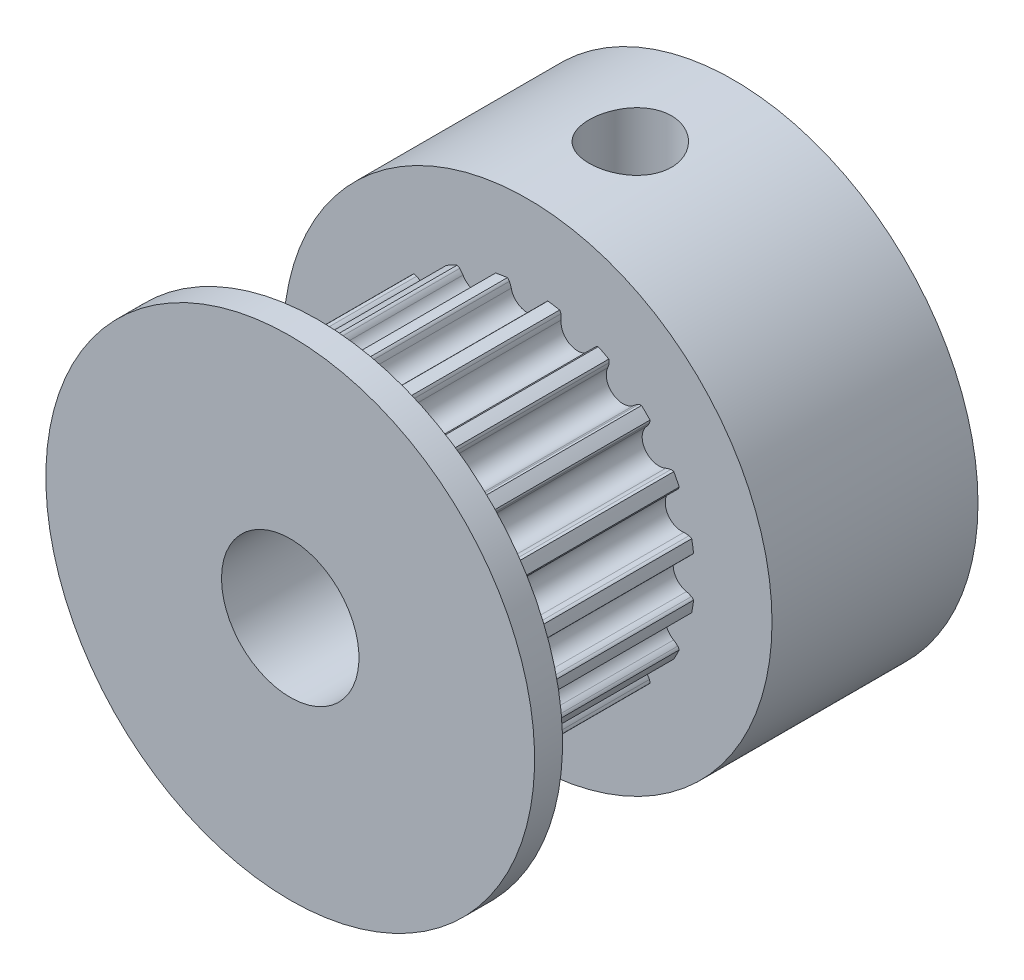
from build123d import *

# Parameters (mm, degrees)
CROQUIS1_W              = 8.89
CROQUIS1_H              = 7.493
SALIENTE_EXTRUIR1_DEPTH = 7.62
CROQUIS3_R              = 8.89
SALIENTE_EXTRUIR2_DEPTH = 1.016
TALADRO1_D              = 5
CROQUIS6_W              = 1.4986
CROQUIS6_H              = 6.09092461
CROQUIS8_W              = 1.4986
CROQUIS8_H              = 6.09092461


with BuildPart() as part:
    # Croquis1 → Revolución1 (revolve)
    with BuildSketch(Plane.XZ.offset(-159)):
        with Locations((120.445, 165.896175008)):
            Rectangle(CROQUIS1_W, CROQUIS1_H)
    revolve(axis=Axis((116, 159, 169.642675008), (0, 0, -1)))

    # Croquis2 → Saliente-Extruir1 (add)
    with BuildSketch(Plane.XY.offset(169.642675008)):
        with BuildLine():
            ThreePointArc((112.121956932, 163.323311365), (112.887977513, 163.283331488), (113.086667767, 164.024214814))
            ThreePointArc((113.086667767, 164.024214814), (113.054039722, 164.114885311), (113.03495398, 164.209338807))
            ThreePointArc((113.03495398, 164.209338807), (113.034584378, 164.263879911), (113.04714549, 164.31695615))
            ThreePointArc((113.04714549, 164.31695615), (113.238880224, 164.419002679), (113.43413645, 164.514137893))
            ThreePointArc((113.43413645, 164.514137893), (113.484459265, 164.493102615), (113.528366698, 164.460745144))
            ThreePointArc((113.528366698, 164.460745144), (113.593562865, 164.389786083), (113.647738554, 164.310094658))
            ThreePointArc((113.647738554, 164.310094658), (114.363912957, 164.035358158), (114.781824157, 164.678581408))
            ThreePointArc((114.781824157, 164.678581408), (114.778811766, 164.774896796), (114.789847882, 164.870625227))
            ThreePointArc((114.789847882, 164.870625227), (114.806350498, 164.922611113), (114.834698285, 164.969208019))
            ThreePointArc((114.834698285, 164.969208019), (115.048582965, 165.007010744), (115.263681069, 165.037152217))
            ThreePointArc((115.263681069, 165.037152217), (115.305040652, 165.001595874), (115.336800094, 164.957253947))
            ThreePointArc((115.336800094, 164.957253947), (115.376877777, 164.869621146), (115.403775915, 164.777088889))
            ThreePointArc((115.403775915, 164.777088889), (116, 164.294488889), (116.596224085, 164.777088889))
            ThreePointArc((116.596224085, 164.777088889), (116.623122223, 164.869621146), (116.663199906, 164.957253947))
            ThreePointArc((116.663199906, 164.957253947), (116.694959348, 165.001595874), (116.736318931, 165.037152217))
            ThreePointArc((116.736318931, 165.037152217), (116.951417035, 165.007010744), (117.165301715, 164.969208019))
            ThreePointArc((117.165301715, 164.969208019), (117.193649502, 164.922611113), (117.210152118, 164.870625227))
            ThreePointArc((117.210152118, 164.870625227), (117.221188234, 164.774896796), (117.218175843, 164.678581408))
            ThreePointArc((117.218175843, 164.678581408), (117.636087043, 164.035358158), (118.352261446, 164.310094658))
            ThreePointArc((118.352261446, 164.310094658), (118.406437135, 164.389786083), (118.471633302, 164.460745144))
            ThreePointArc((118.471633302, 164.460745144), (118.515540735, 164.493102615), (118.56586355, 164.514137893))
            ThreePointArc((118.56586355, 164.514137893), (118.761119776, 164.419002679), (118.95285451, 164.31695615))
            ThreePointArc((118.95285451, 164.31695615), (118.965415622, 164.263879911), (118.96504602, 164.209338807))
            ThreePointArc((118.96504602, 164.209338807), (118.945960278, 164.114885311), (118.913332233, 164.024214814))
            ThreePointArc((118.913332233, 164.024214814), (119.112022487, 163.283331488), (119.878043068, 163.323311365))
            ThreePointArc((119.878043068, 163.323311365), (119.954193214, 163.382361205), (120.038126009, 163.429700559))
            ThreePointArc((120.038126009, 163.429700559), (120.089883468, 163.4469062), (120.144243567, 163.451361332))
            ThreePointArc((120.144243567, 163.451361332), (120.300544876, 163.300544876), (120.451361332, 163.144243567))
            ThreePointArc((120.451361332, 163.144243567), (120.4469062, 163.089883468), (120.429700559, 163.038126009))
            ThreePointArc((120.429700559, 163.038126009), (120.382361205, 162.954193214), (120.323311365, 162.878043068))
            ThreePointArc((120.323311365, 162.878043068), (120.283331488, 162.112022487), (121.024214814, 161.913332233))
            ThreePointArc((121.024214814, 161.913332233), (121.114885311, 161.945960278), (121.209338807, 161.96504602))
            ThreePointArc((121.209338807, 161.96504602), (121.263879911, 161.965415622), (121.31695615, 161.95285451))
            ThreePointArc((121.31695615, 161.95285451), (121.419002679, 161.761119776), (121.514137893, 161.56586355))
            ThreePointArc((121.514137893, 161.56586355), (121.493102615, 161.515540735), (121.460745144, 161.471633302))
            ThreePointArc((121.460745144, 161.471633302), (121.389786083, 161.406437135), (121.310094658, 161.352261446))
            ThreePointArc((121.310094658, 161.352261446), (121.035358158, 160.636087043), (121.678581408, 160.218175843))
            ThreePointArc((121.678581408, 160.218175843), (121.774896796, 160.221188234), (121.870625227, 160.210152118))
            ThreePointArc((121.870625227, 160.210152118), (121.922611113, 160.193649502), (121.969208019, 160.165301715))
            ThreePointArc((121.969208019, 160.165301715), (122.007010744, 159.951417035), (122.037152217, 159.736318931))
            ThreePointArc((122.037152217, 159.736318931), (122.001595874, 159.694959348), (121.957253947, 159.663199906))
            ThreePointArc((121.957253947, 159.663199906), (121.869621146, 159.623122223), (121.777088889, 159.596224085))
            ThreePointArc((121.777088889, 159.596224085), (121.294488889, 159), (121.777088889, 158.403775915))
            ThreePointArc((121.777088889, 158.403775915), (121.869621146, 158.376877777), (121.957253947, 158.336800094))
            ThreePointArc((121.957253947, 158.336800094), (122.001595874, 158.305040652), (122.037152217, 158.263681069))
            ThreePointArc((122.037152217, 158.263681069), (122.007010744, 158.048582965), (121.969208019, 157.834698285))
            ThreePointArc((121.969208019, 157.834698285), (121.922611113, 157.806350498), (121.870625227, 157.789847882))
            ThreePointArc((121.870625227, 157.789847882), (121.774896796, 157.778811766), (121.678581408, 157.781824157))
            ThreePointArc((121.678581408, 157.781824157), (121.035358158, 157.363912957), (121.310094658, 156.647738554))
            ThreePointArc((121.310094658, 156.647738554), (121.389786083, 156.593562865), (121.460745144, 156.528366698))
            ThreePointArc((121.460745144, 156.528366698), (121.493102615, 156.484459265), (121.514137893, 156.43413645))
            ThreePointArc((121.514137893, 156.43413645), (121.419002679, 156.238880224), (121.31695615, 156.04714549))
            ThreePointArc((121.31695615, 156.04714549), (121.263879911, 156.034584378), (121.209338807, 156.03495398))
            ThreePointArc((121.209338807, 156.03495398), (121.114885311, 156.054039722), (121.024214814, 156.086667767))
            ThreePointArc((121.024214814, 156.086667767), (120.283331488, 155.887977513), (120.323311365, 155.121956932))
            ThreePointArc((120.323311365, 155.121956932), (120.382361205, 155.045806786), (120.429700559, 154.961873991))
            ThreePointArc((120.429700559, 154.961873991), (120.4469062, 154.910116532), (120.451361332, 154.855756433))
            ThreePointArc((120.451361332, 154.855756433), (120.300544876, 154.699455124), (120.144243567, 154.548638668))
            ThreePointArc((120.144243567, 154.548638668), (120.089883468, 154.5530938), (120.038126009, 154.570299441))
            ThreePointArc((120.038126009, 154.570299441), (119.954193214, 154.617638795), (119.878043068, 154.676688635))
            ThreePointArc((119.878043068, 154.676688635), (119.112022487, 154.716668512), (118.913332233, 153.975785186))
            ThreePointArc((118.913332233, 153.975785186), (118.945960278, 153.885114689), (118.96504602, 153.790661193))
            ThreePointArc((118.96504602, 153.790661193), (118.965415622, 153.736120089), (118.95285451, 153.68304385))
            ThreePointArc((118.95285451, 153.68304385), (118.761119776, 153.580997321), (118.56586355, 153.485862107))
            ThreePointArc((118.56586355, 153.485862107), (118.515540735, 153.506897385), (118.471633302, 153.539254856))
            ThreePointArc((118.471633302, 153.539254856), (118.406437135, 153.610213917), (118.352261446, 153.689905342))
            ThreePointArc((118.352261446, 153.689905342), (117.636087043, 153.964641842), (117.218175843, 153.321418592))
            ThreePointArc((117.218175843, 153.321418592), (117.221188234, 153.225103204), (117.210152118, 153.129374773))
            ThreePointArc((117.210152118, 153.129374773), (117.193649502, 153.077388887), (117.165301715, 153.030791981))
            ThreePointArc((117.165301715, 153.030791981), (116.951417035, 152.992989256), (116.736318931, 152.962847783))
            ThreePointArc((116.736318931, 152.962847783), (116.694959348, 152.998404126), (116.663199906, 153.042746053))
            ThreePointArc((116.663199906, 153.042746053), (116.623122223, 153.130378854), (116.596224085, 153.222911111))
            ThreePointArc((116.596224085, 153.222911111), (116, 153.705511111), (115.403775915, 153.222911111))
            ThreePointArc((115.403775915, 153.222911111), (115.376877777, 153.130378854), (115.336800094, 153.042746053))
            ThreePointArc((115.336800094, 153.042746053), (115.305040652, 152.998404126), (115.263681069, 152.962847783))
            ThreePointArc((115.263681069, 152.962847783), (115.048582965, 152.992989256), (114.834698285, 153.030791981))
            ThreePointArc((114.834698285, 153.030791981), (114.806350498, 153.077388887), (114.789847882, 153.129374773))
            ThreePointArc((114.789847882, 153.129374773), (114.778811766, 153.225103204), (114.781824157, 153.321418592))
            ThreePointArc((114.781824157, 153.321418592), (114.363912957, 153.964641842), (113.647738554, 153.689905342))
            ThreePointArc((113.647738554, 153.689905342), (113.593562865, 153.610213917), (113.528366698, 153.539254856))
            ThreePointArc((113.528366698, 153.539254856), (113.484459265, 153.506897385), (113.43413645, 153.485862107))
            ThreePointArc((113.43413645, 153.485862107), (113.238880224, 153.580997321), (113.04714549, 153.68304385))
            ThreePointArc((113.04714549, 153.68304385), (113.034584378, 153.736120089), (113.03495398, 153.790661193))
            ThreePointArc((113.03495398, 153.790661193), (113.054039722, 153.885114689), (113.086667767, 153.975785186))
            ThreePointArc((113.086667767, 153.975785186), (112.887977513, 154.716668512), (112.121956932, 154.676688635))
            ThreePointArc((112.121956932, 154.676688635), (112.045806786, 154.617638795), (111.961873991, 154.570299441))
            ThreePointArc((111.961873991, 154.570299441), (111.910116532, 154.5530938), (111.855756433, 154.548638668))
            ThreePointArc((111.855756433, 154.548638668), (111.699455124, 154.699455124), (111.548638668, 154.855756433))
            ThreePointArc((111.548638668, 154.855756433), (111.5530938, 154.910116532), (111.570299441, 154.961873991))
            ThreePointArc((111.570299441, 154.961873991), (111.617638795, 155.045806786), (111.676688635, 155.121956932))
            ThreePointArc((111.676688635, 155.121956932), (111.716668512, 155.887977513), (110.975785186, 156.086667767))
            ThreePointArc((110.975785186, 156.086667767), (110.885114689, 156.054039722), (110.790661193, 156.03495398))
            ThreePointArc((110.790661193, 156.03495398), (110.736120089, 156.034584378), (110.68304385, 156.04714549))
            ThreePointArc((110.68304385, 156.04714549), (110.580997321, 156.238880224), (110.485862107, 156.43413645))
            ThreePointArc((110.485862107, 156.43413645), (110.506897385, 156.484459265), (110.539254856, 156.528366698))
            ThreePointArc((110.539254856, 156.528366698), (110.610213917, 156.593562865), (110.689905342, 156.647738554))
            ThreePointArc((110.689905342, 156.647738554), (110.964641842, 157.363912957), (110.321418592, 157.781824157))
            ThreePointArc((110.321418592, 157.781824157), (110.225103204, 157.778811766), (110.129374773, 157.789847882))
            ThreePointArc((110.129374773, 157.789847882), (110.077388887, 157.806350498), (110.030791981, 157.834698285))
            ThreePointArc((110.030791981, 157.834698285), (109.992989256, 158.048582965), (109.962847783, 158.263681069))
            ThreePointArc((109.962847783, 158.263681069), (109.998404126, 158.305040652), (110.042746053, 158.336800094))
            ThreePointArc((110.042746053, 158.336800094), (110.130378854, 158.376877777), (110.222911111, 158.403775915))
            ThreePointArc((110.222911111, 158.403775915), (110.705511111, 159), (110.222911111, 159.596224085))
            ThreePointArc((110.222911111, 159.596224085), (110.130378854, 159.623122223), (110.042746053, 159.663199906))
            ThreePointArc((110.042746053, 159.663199906), (109.998404126, 159.694959348), (109.962847783, 159.736318931))
            ThreePointArc((109.962847783, 159.736318931), (109.992989256, 159.951417035), (110.030791981, 160.165301715))
            ThreePointArc((110.030791981, 160.165301715), (110.077388887, 160.193649502), (110.129374773, 160.210152118))
            ThreePointArc((110.129374773, 160.210152118), (110.225103204, 160.221188234), (110.321418592, 160.218175843))
            ThreePointArc((110.321418592, 160.218175843), (110.964641842, 160.636087043), (110.689905342, 161.352261446))
            ThreePointArc((110.689905342, 161.352261446), (110.610213917, 161.406437135), (110.539254856, 161.471633302))
            ThreePointArc((110.539254856, 161.471633302), (110.506897385, 161.515540735), (110.485862107, 161.56586355))
            ThreePointArc((110.485862107, 161.56586355), (110.580997321, 161.761119776), (110.68304385, 161.95285451))
            ThreePointArc((110.68304385, 161.95285451), (110.736120089, 161.965415622), (110.790661193, 161.96504602))
            ThreePointArc((110.790661193, 161.96504602), (110.885114689, 161.945960278), (110.975785186, 161.913332233))
            ThreePointArc((110.975785186, 161.913332233), (111.716668512, 162.112022487), (111.676688635, 162.878043068))
            ThreePointArc((111.676688635, 162.878043068), (111.617638795, 162.954193214), (111.570299441, 163.038126009))
            ThreePointArc((111.570299441, 163.038126009), (111.5530938, 163.089883468), (111.548638668, 163.144243567))
            ThreePointArc((111.548638668, 163.144243567), (111.699455124, 163.300544876), (111.855756433, 163.451361332))
            ThreePointArc((111.855756433, 163.451361332), (111.910116532, 163.4469062), (111.961873991, 163.429700559))
            ThreePointArc((111.961873991, 163.429700559), (112.045806786, 163.382361205), (112.121956932, 163.323311365))
        make_face()
    extrude(amount=SALIENTE_EXTRUIR1_DEPTH)

    # Croquis3 → Saliente-Extruir2 (add)
    with BuildSketch(Plane(origin=(0, 0, 177.262675008), x_dir=(-1, 0, 0), z_dir=(0, 0, -1))):
        with Locations((-116, 159)):
            Circle(CROQUIS3_R)
    extrude(amount=-SALIENTE_EXTRUIR2_DEPTH)

    # Taladro1 (through all)
    with Locations(Plane(origin=(0, 0, 162.149675008), x_dir=(-1, 0, 0), z_dir=(0, 0, -1))):
        with Locations((-116, 159)):
            Hole(TALADRO1_D / 2)

    # Croquis6 → Taladro2 (revolve, cut)
    with BuildSketch(Plane(origin=(116, 161.79907539, 165.908875008), x_dir=(0, 0, -1), z_dir=(1, 0, 0))):
        with Locations((0.7493, 3.045462305)):
            Rectangle(CROQUIS6_W, CROQUIS6_H)
    revolve(axis=Axis((116, 271.79907539, 165.908875008), (0, -1, 0)), mode=Mode.SUBTRACT)

    # Croquis8 → Taladro3 (revolve, cut)
    with BuildSketch(Plane(origin=(113.20092461, 159, 165.908875008), x_dir=(0, 0, -1), z_dir=(0, 1, 0))):
        with Locations((0.7493, 3.045462305)):
            Rectangle(CROQUIS8_W, CROQUIS8_H)
    revolve(axis=Axis((3.20092461, 159, 165.908875008), (1, 0, 0)), mode=Mode.SUBTRACT)


solid = part.part
